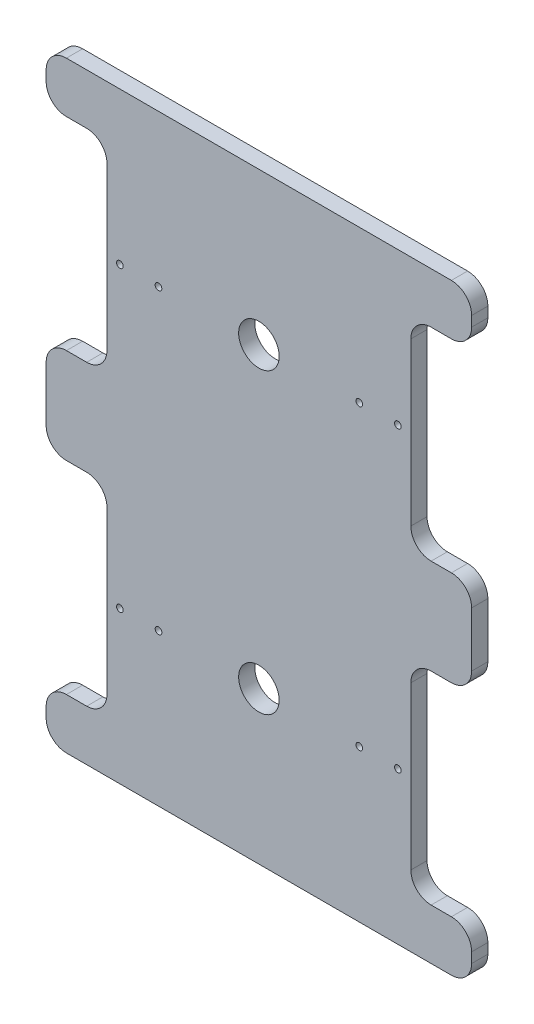
from build123d import *

# Parameters (mm, degrees)
P_IDAT_VYSUNUT_M2_DEPTH  = 8
ZAOBLIT1_R               = 10
SKICA2_R                 = 1.65
SKICA2_R_2               = 10
ODEBRAT_VYSUNUT_M1_DEPTH = 8


with BuildPart() as part:
    # Skica1 → Přidat vysunutím2 (new body)
    with BuildSketch(Plane.XY):
        Polygon((0, 0), (210, 0), (210, 25), (180, 25), (180, 125), (210, 125), (210, 172), (180, 172), (180, 272), (210, 272), (210, 297), (0, 297), (0, 272), (30, 272), (30, 172), (0, 172), (0, 125), (30, 125), (30, 25), (0, 25), align=None)
    extrude(amount=P_IDAT_VYSUNUT_M2_DEPTH)

    # Zaoblit1
    zaoblit1_edges = [part.edges().sort_by_distance(p)[0] for p in [
        (0, 25, 4),
        (30, 25, 4),
        (30, 125, 4),
        (0, 125, 4),
        (0, 172, 4),
        (30, 172, 4),
        (30, 272, 4),
        (0, 272, 4),
        (0, 297, 4),
        (210, 297, 4),
        (210, 272, 4),
        (180, 272, 4),
        (180, 172, 4),
        (210, 172, 4),
        (210, 125, 4),
        (180, 125, 4),
        (180, 25, 4),
        (210, 25, 4),
        (210, 0, 4),
        (0, 0, 4),
    ]]
    fillet(zaoblit1_edges, radius=ZAOBLIT1_R)

    # Skica2 → Odebrat vysunutím1 (cut)
    with BuildSketch(Plane(origin=(0, 0, 0), x_dir=(-1, 0, 0), z_dir=(0, 0, -1))):
        with Locations((-173.6, 222)):
            Circle(SKICA2_R)
        with Locations((-36.4, 222)):
            Circle(SKICA2_R)
        with Locations((-55.45, 222)):
            Circle(SKICA2_R)
        with Locations((-154.55, 222)):
            Circle(SKICA2_R)
        with Locations((-173.6, 75)):
            Circle(SKICA2_R)
        with Locations((-154.55, 75)):
            Circle(SKICA2_R)
        with Locations((-55.45, 75)):
            Circle(SKICA2_R)
        with Locations((-36.4, 75)):
            Circle(SKICA2_R)
        with Locations((-105, 75)):
            Circle(SKICA2_R_2)
        with Locations((-105, 222)):
            Circle(SKICA2_R_2)
    extrude(amount=-ODEBRAT_VYSUNUT_M1_DEPTH, mode=Mode.SUBTRACT)


solid = part.part
